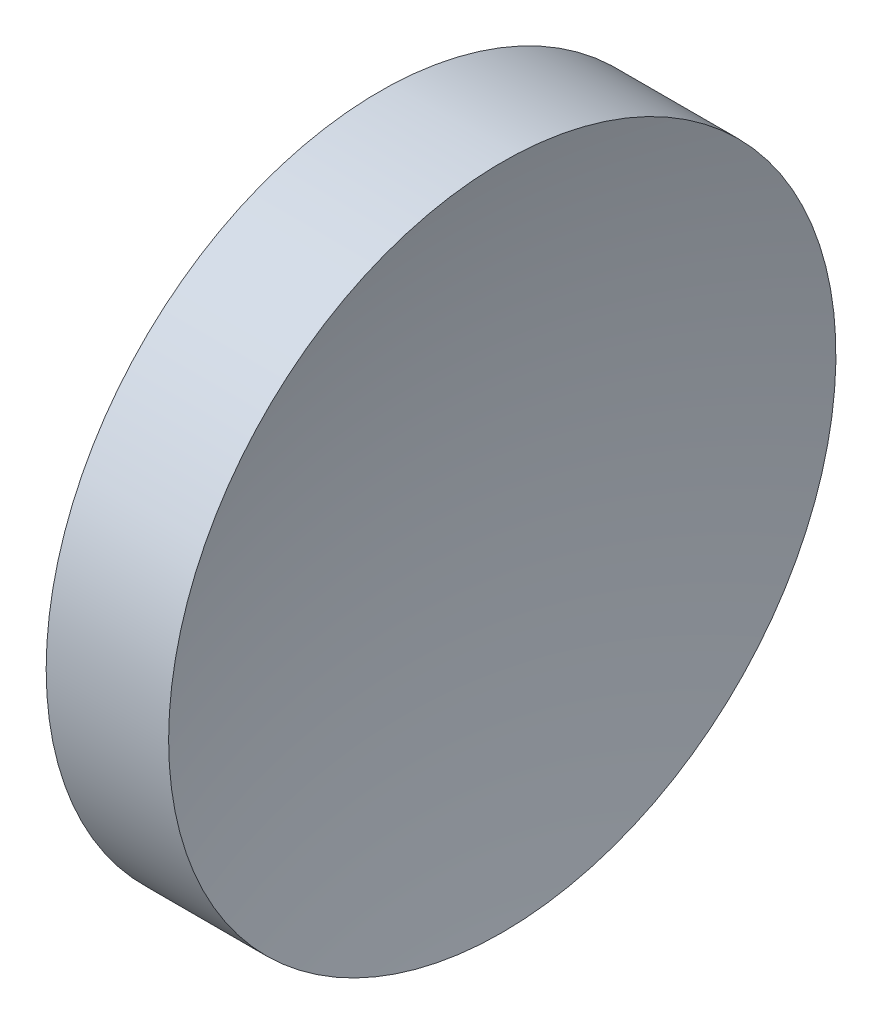
from build123d import *


with BuildPart() as part:
    # 草图1 → 旋转1 (revolve)
    with BuildSketch(Plane.XY, mode=Mode.PRIVATE) as revolve_1_sk:
        with BuildLine():
            Line((230.199611905, 138.756042247), (230.199611905, 176.256042247))
            Line((230.199611905, 176.256042247), (243.962736422, 176.256042247))
            ThreePointArc((243.962736422, 176.256042247), (240.395157465, 157.656686119), (239.199611905, 138.756042247))
            Line((239.199611905, 138.756042247), (230.199611905, 138.756042247))
        make_face()
    revolve(revolve_1_sk.sketch.rotate(Axis((217.970286004, 138.756042247, 0), (1, 0, 0)), 180), axis=Axis((217.970286004, 138.756042247, 0), (1, 0, 0)))  # turned: the seam where the file's is


solid = part.part
